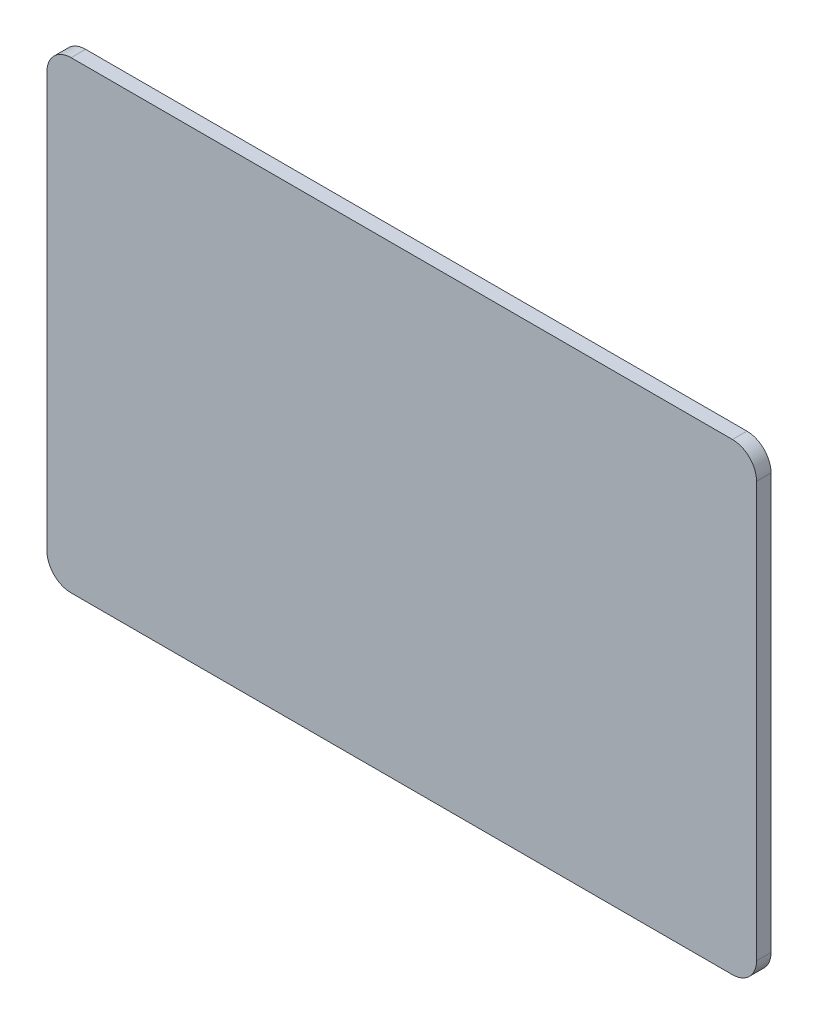
from build123d import *

# Parameters (mm, degrees)
EXTRUDE_1_DEPTH = 30
EXTRUDE_2_DEPTH = 100


with BuildPart() as part:
    # 草图2 → 凸台-拉伸1 (new body)
    with BuildSketch(Plane.XY):
        with BuildLine():
            Line((-1075.548373655, 479.992677665), (293.974322669, 479.992677665))
            ThreePointArc((293.974322669, 479.992677665), (329.329661728, 465.348016724), (343.974322669, 429.992677665))
            Line((343.974322669, 429.992677665), (343.974322669, -429.992677665))
            ThreePointArc((343.974322669, -429.992677665), (329.329661728, -465.348016724), (293.974322669, -479.992677665))
            Line((293.974322669, -479.992677665), (-1075.548373655, -479.992677665))
            ThreePointArc((-1075.548373655, -479.992677665), (-1110.903712715, -465.348016724), (-1125.548373655, -429.992677665))
            Line((-1125.548373655, -429.992677665), (-1125.548373655, 429.992677665))
            ThreePointArc((-1125.548373655, 429.992677665), (-1110.903712715, 465.348016724), (-1075.548373655, 479.992677665))
        make_face()
    extrude(amount=EXTRUDE_1_DEPTH)

    # 草图4 → 凸台-拉伸2 (add)
    with BuildSketch(Plane(origin=(0, 0, 0), x_dir=(-1, 0, 0), z_dir=(0, 0, -1))):
        with BuildLine():
            Line((510, 200), (810, 200))
            ThreePointArc((810, 200), (845.355339059, 185.355339059), (860, 150))
            Line((860, 150), (860, -150))
            ThreePointArc((860, -150), (845.355339059, -185.355339059), (810, -200))
            Line((810, -200), (510, -200))
            ThreePointArc((510, -200), (474.644660941, -185.355339059), (460, -150))
            Line((460, -150), (460, 150))
            ThreePointArc((460, 150), (474.644660941, 185.355339059), (510, 200))
        make_face()
    extrude(amount=EXTRUDE_2_DEPTH)


solid = part.part
